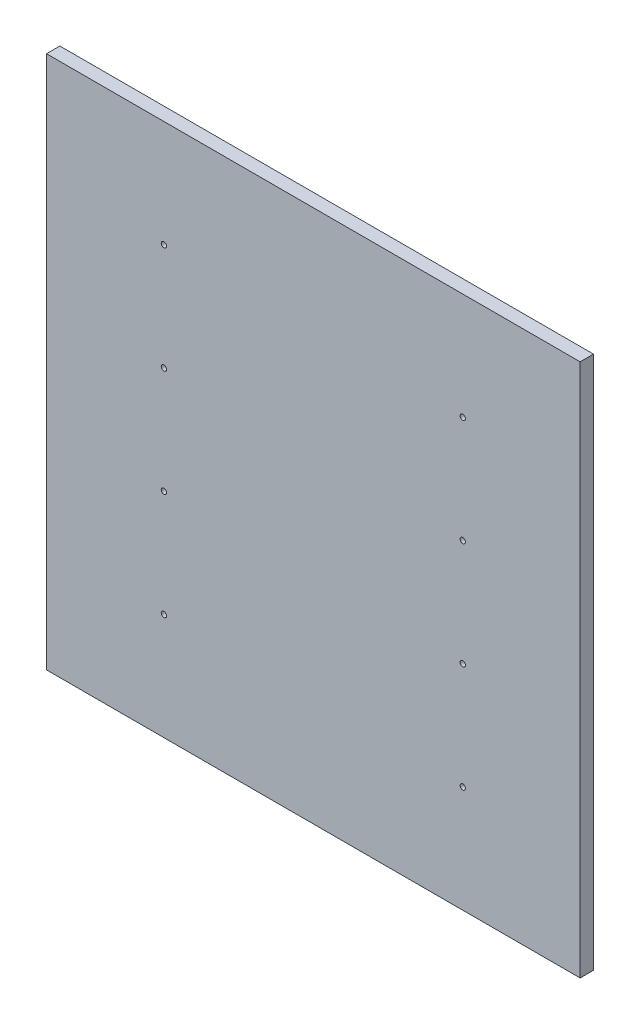
from build123d import *

# Parameters (mm, degrees)
SKETCH1_W           = 40
SKETCH1_H           = 40
BOSS_EXTRUDE1_DEPTH = 1
SKETCH2_R           = 0.2
CUT_EXTRUDE1_DEPTH  = 1


with BuildPart() as part:
    # Sketch1 → Boss-Extrude1 (new body)
    with BuildSketch(Plane.XY):
        with Locations((25, -25)):
            Rectangle(SKETCH1_W, SKETCH1_H)
    extrude(amount=BOSS_EXTRUDE1_DEPTH)

    # Sketch2 → Cut-Extrude1 (cut)
    with BuildSketch(Plane.XY.offset(1)):
        with Locations((13.8, -13)):
            Circle(SKETCH2_R)
        with Locations((36.2, -13)):
            Circle(SKETCH2_R)
        with Locations((36.2, -21)):
            Circle(SKETCH2_R)
        with Locations((13.8, -21)):
            Circle(SKETCH2_R)
        with Locations((13.8, -29)):
            Circle(SKETCH2_R)
        with Locations((36.2, -29)):
            Circle(SKETCH2_R)
        with Locations((36.2, -37)):
            Circle(SKETCH2_R)
        with Locations((13.8, -37)):
            Circle(SKETCH2_R)
    extrude(amount=-CUT_EXTRUDE1_DEPTH, mode=Mode.SUBTRACT)


solid = part.part
